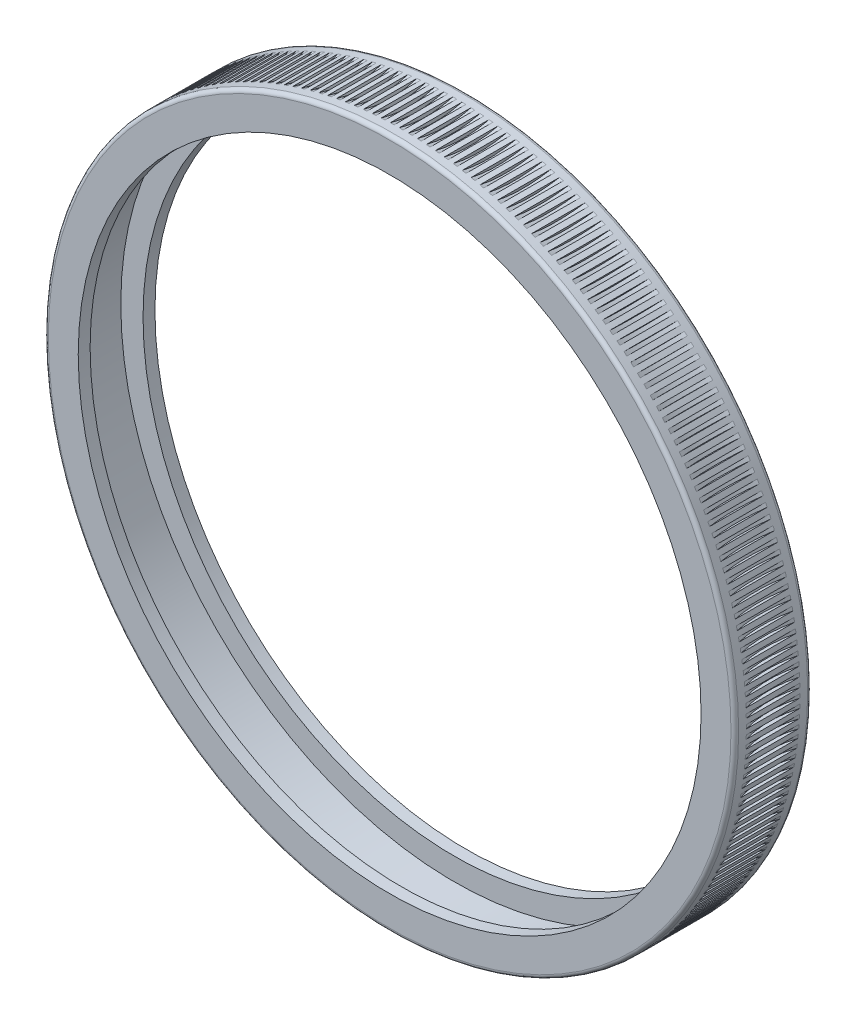
from build123d import *

# Parameters (mm, degrees)
SKETCH1_R           = 45
SKETCH1_R_2         = 40.6
BOSS_EXTRUDE1_DEPTH = 1.55
SKETCH2_R           = 45
SKETCH2_R_2         = 43.5
BOSS_EXTRUDE2_DEPTH = 6.9
SKETCH3_R           = 45
SKETCH3_R_2         = 40.6
BOSS_EXTRUDE3_DEPTH = 1.55
FILLET1_R           = 0.5
SKETCH4_R           = 12.5
CUT_EXTRUDE1_DEPTH  = 0.25
CIRPATTERN1_COUNT   = 240


with BuildPart() as part:
    # Sketch1 → Boss-Extrude1 (new body)
    with BuildSketch(Plane.XY):
        with Locations(Location((0, 0, 0), (0, 0, 180))):
            Circle(SKETCH1_R)
        with Locations(Location((0, 0, 0), (0, 0, 180))):
            Circle(SKETCH1_R_2, mode=Mode.SUBTRACT)
    extrude(amount=BOSS_EXTRUDE1_DEPTH)

    # Sketch2 → Boss-Extrude2 (add)
    with BuildSketch(Plane.XY.offset(1.55)):
        with Locations(Location((0, 0, 0), (0, 0, 180))):
            Circle(SKETCH2_R)
        with Locations(Location((0, 0, 0), (0, 0, 180))):
            Circle(SKETCH2_R_2, mode=Mode.SUBTRACT)
    extrude(amount=BOSS_EXTRUDE2_DEPTH)

    # Sketch3 → Boss-Extrude3 (add)
    with BuildSketch(Plane.XY.offset(8.45)):
        with Locations(Location((0, 0, 0), (0, 0, 180))):
            Circle(SKETCH3_R)
        with Locations(Location((0, 0, 0), (0, 0, 180))):
            Circle(SKETCH3_R_2, mode=Mode.SUBTRACT)
    extrude(amount=BOSS_EXTRUDE3_DEPTH)

    # Fillet1
    fillet1_edges = [part.edges().sort_by_distance(p)[0] for p in [
        (45, 0, 10),
        (45, 0, 0),
    ]]
    fillet(fillet1_edges, radius=FILLET1_R)

    # Sketch4 → Cut-Extrude1 (cut, symmetric)
    with BuildSketch(Plane(origin=(0, 0, 0), x_dir=(1, 0, 0), z_dir=(0, 1, 0))):
        with Locations((-57, -5)):
            Circle(SKETCH4_R)
    cut_extrude1 = extrude(amount=CUT_EXTRUDE1_DEPTH, both=True, mode=Mode.SUBTRACT)

    # CirPattern1: Cut-Extrude1 ×240 about axis
    cirpattern1_axis = Axis((0, 0, 0), (0, 0, 1))
    for i in range(1, CIRPATTERN1_COUNT):
        add(cut_extrude1.rotate(cirpattern1_axis, i * 360 / CIRPATTERN1_COUNT), mode=Mode.SUBTRACT)


solid = part.part
